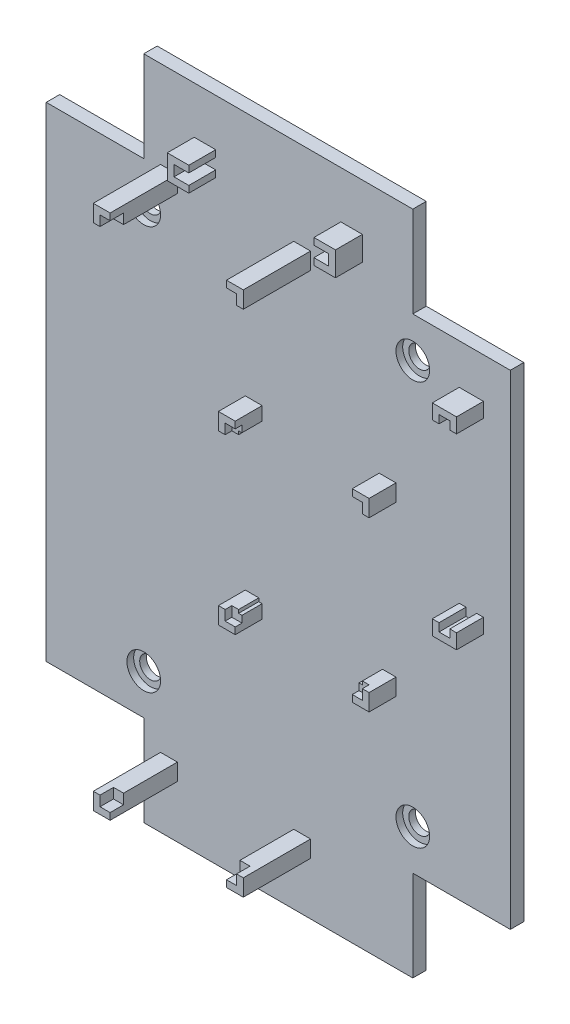
from build123d import *

# Parameters (mm, degrees)
BOSS_EXTRUDE1_DEPTH = 2
SKETCH2_R           = 1.6
CUT_EXTRUDE1_DEPTH  = 2
SKETCH5_R           = 2.5
CUT_EXTRUDE2_DEPTH  = 1
SKETCH6_W           = 25
SKETCH6_H           = 3.6
SKETCH6_W_2         = 23
SKETCH6_H_2         = 1.6
BOSS_EXTRUDE2_DEPTH = 4
SKETCH7_W           = 18.6
SKETCH7_H           = 4
CUT_EXTRUDE3_DEPTH  = 15
SKETCH9_W           = 3.6
SKETCH9_H           = 30
SKETCH9_W_2         = 1.6
SKETCH9_H_2         = 28
BOSS_EXTRUDE4_DEPTH = 4
SKETCH10_W          = 4
SKETCH10_H          = 25.6
CUT_EXTRUDE4_DEPTH  = 4
SKETCH11_W          = 22.4
SKETCH11_H          = 27.5
SKETCH11_W_2        = 20.4
SKETCH11_H_2        = 25.5
BOSS_EXTRUDE5_DEPTH = 4
SKETCH12_W          = 20.4
SKETCH12_H          = 25.5
BOSS_EXTRUDE6_DEPTH = 3
SKETCH13_W          = 18.4
SKETCH13_H          = 23.5
CUT_EXTRUDE5_DEPTH  = 3
SKETCH14_W          = 4
SKETCH14_H          = 22.5
CUT_EXTRUDE6_DEPTH  = 30
SKETCH15_W          = 17.4
SKETCH15_H          = 4
CUT_EXTRUDE7_DEPTH  = 30
SKETCH16_W          = 22.3
SKETCH16_H          = 78.2
SKETCH16_W_2        = 20.3
SKETCH16_H_2        = 76.2
BOSS_EXTRUDE7_DEPTH = 10
SKETCH17_W          = 17.3
SKETCH17_H          = 10
CUT_EXTRUDE8_DEPTH  = 10
CUT_EXTRUDE9_REACH  = 95.2
SKETCH18_W          = 17.3
SKETCH18_H          = 10
CUT_EXTRUDE10_REACH = 96.44
SKETCH19_W          = 10
SKETCH19_H          = 73.2
CUT_EXTRUDE11_REACH = 90.088
SKETCH20_W          = 10
SKETCH20_H          = 73.2
SKETCH21_W          = 1.5
SKETCH21_H          = 1.5
BOSS_EXTRUDE8_DEPTH = 8


with BuildPart() as part:
    # 3DSketch1 → Boss-Extrude1 (new body)
    with BuildSketch(Plane(origin=(-20, 20.801620861, 0), x_dir=(0.3746178943835793, -0.927179288599359, 0), z_dir=(0, 0, 1))):
        Polygon((0, 0), (14.984715775, 37.087171544), (27.501636171, 32.02982997), (32.93359564, 45.473929654), (99.690504419, 18.501441259), (94.258544951, 5.057341574), (106.775465347, 0), (91.790749571, -37.087171544), (79.273829175, -32.02982997), (73.841869707, -45.473929654), (7.084960928, -18.501441259), (12.516920396, -5.057341574), align=None)
    extrude(amount=-BOSS_EXTRUDE1_DEPTH)

    # Sketch2 → Cut-Extrude1 (cut)
    with BuildSketch(Plane.XY):
        with Locations((-20, 1.301620861)):
            Circle(SKETCH2_R)
        with Locations((20, 1.301620861)):
            Circle(SKETCH2_R)
        with Locations((20, -58.698379139)):
            Circle(SKETCH2_R)
        with Locations((-20, -58.698379139)):
            Circle(SKETCH2_R)
    extrude(amount=-CUT_EXTRUDE1_DEPTH, mode=Mode.SUBTRACT)

    # Sketch5 → Cut-Extrude2 (cut)
    with BuildSketch(Plane.XY):
        with Locations((-20, 1.301620861)):
            Circle(SKETCH5_R)
        with Locations((20, 1.301620861)):
            Circle(SKETCH5_R)
        with Locations((20, -58.698379139)):
            Circle(SKETCH5_R)
        with Locations((-20, -58.698379139)):
            Circle(SKETCH5_R)
    extrude(amount=-CUT_EXTRUDE2_DEPTH, mode=Mode.SUBTRACT)

    # Sketch6 → Boss-Extrude2 (add)
    with BuildSketch(Plane.XY):
        with Locations((0, 12.001620861)):
            Rectangle(SKETCH6_W, SKETCH6_H)
        with Locations((0, 12.001620861)):
            Rectangle(SKETCH6_W_2, SKETCH6_H_2, mode=Mode.SUBTRACT)
    extrude(amount=BOSS_EXTRUDE2_DEPTH)

    # Sketch7 → Cut-Extrude3 (cut)
    with BuildSketch(Plane(origin=(0, 13.801620861, 0), x_dir=(1, 0, 0), z_dir=(0, 1, 0))):
        with Locations((0, -2)):
            Rectangle(SKETCH7_W, SKETCH7_H)
    extrude(amount=-CUT_EXTRUDE3_DEPTH, mode=Mode.SUBTRACT)

    # Sketch9 → Boss-Extrude4 (add)
    with BuildSketch(Plane.XY):
        with Locations((28.7, -13.698379139)):
            Rectangle(SKETCH9_W, SKETCH9_H)
        with Locations((28.7, -13.698379139)):
            Rectangle(SKETCH9_W_2, SKETCH9_H_2, mode=Mode.SUBTRACT)
    extrude(amount=BOSS_EXTRUDE4_DEPTH)

    # Sketch10 → Cut-Extrude4 (cut)
    with BuildSketch(Plane(origin=(30.5, 0, 0), x_dir=(0, 0, -1), z_dir=(1, 0, 0))):
        with Locations((-2, -13.698379139)):
            Rectangle(SKETCH10_W, SKETCH10_H)
    extrude(amount=-CUT_EXTRUDE4_DEPTH, mode=Mode.SUBTRACT)

    # Sketch11 → Boss-Extrude5 (add)
    with BuildSketch(Plane.XY):
        with Locations((6.3, -29.448379139)):
            Rectangle(SKETCH11_W, SKETCH11_H)
        with Locations((6.3, -29.448379139)):
            Rectangle(SKETCH11_W_2, SKETCH11_H_2, mode=Mode.SUBTRACT)
    extrude(amount=BOSS_EXTRUDE5_DEPTH)

    # Sketch12 → Boss-Extrude6 (add)
    with BuildSketch(Plane.XY):
        with Locations((6.3, -29.448379139)):
            Rectangle(SKETCH12_W, SKETCH12_H)
    extrude(amount=BOSS_EXTRUDE6_DEPTH)

    # Sketch13 → Cut-Extrude5 (cut)
    with BuildSketch(Plane.XY.offset(3)):
        with Locations((6.3, -29.448379139)):
            Rectangle(SKETCH13_W, SKETCH13_H)
    extrude(amount=-CUT_EXTRUDE5_DEPTH, mode=Mode.SUBTRACT)

    # Sketch14 → Cut-Extrude6 (cut)
    with BuildSketch(Plane.ZY.offset(4.9)):
        with Locations((2, -29.448379139)):
            Rectangle(SKETCH14_W, SKETCH14_H)
    extrude(amount=-CUT_EXTRUDE6_DEPTH, mode=Mode.SUBTRACT)

    # Sketch15 → Cut-Extrude7 (cut)
    with BuildSketch(Plane.XZ.offset(43.198379139)):
        with Locations((6.3, 2)):
            Rectangle(SKETCH15_W, SKETCH15_H)
    extrude(amount=-CUT_EXTRUDE7_DEPTH, mode=Mode.SUBTRACT)

    # Sketch16 → Boss-Extrude7 (add)
    with BuildSketch(Plane.XY):
        with Locations((-6.35, -31.298379139)):
            Rectangle(SKETCH16_W, SKETCH16_H)
        with Locations((-6.35, -31.298379139)):
            Rectangle(SKETCH16_W_2, SKETCH16_H_2, mode=Mode.SUBTRACT)
    extrude(amount=BOSS_EXTRUDE7_DEPTH)

    # Sketch17 → Cut-Extrude8 (cut)
    with BuildSketch(Plane.XZ.offset(70.398379139)):
        with Locations((-6.35, 5)):
            Rectangle(SKETCH17_W, SKETCH17_H)
    extrude(amount=-CUT_EXTRUDE8_DEPTH, mode=Mode.SUBTRACT)

    # Sketch18 → Cut-Extrude9 (cut, up to next)
    with BuildSketch(Plane(origin=(0, 7.801620861, 0), x_dir=(1, 0, 0), z_dir=(0, 1, 0)), mode=Mode.PRIVATE) as cut_extrude9_sk1:
        with Locations((-6.35, -5)):
            Rectangle(SKETCH18_W, SKETCH18_H)
    cut_extrude9_tool1 = extrude(cut_extrude9_sk1.sketch, amount=-CUT_EXTRUDE9_REACH, mode=Mode.PRIVATE) & part.part
    add(cut_extrude9_tool1.solids().sort_by_distance((-6.35, 7.801621, 5))[0], mode=Mode.SUBTRACT)

    # Sketch19 → Cut-Extrude10 (cut, up to next)
    with BuildSketch(Plane.ZY.offset(17.5), mode=Mode.PRIVATE) as cut_extrude10_sk1:
        with Locations((5, -31.298379139)):
            Rectangle(SKETCH19_W, SKETCH19_H)
    cut_extrude10_tool1 = extrude(cut_extrude10_sk1.sketch, amount=-CUT_EXTRUDE10_REACH, mode=Mode.PRIVATE) & part.part
    add(cut_extrude10_tool1.solids().sort_by_distance((-17.5, -31.298379, 5))[0], mode=Mode.SUBTRACT)

    # Sketch20 → Cut-Extrude11 (cut, up to next)
    with BuildSketch(Plane(origin=(4.8, 0, 0), x_dir=(0, 0, -1), z_dir=(1, 0, 0)), mode=Mode.PRIVATE) as cut_extrude11_sk1:
        with Locations((-5, -31.298379139)):
            Rectangle(SKETCH20_W, SKETCH20_H)
    cut_extrude11_tool1 = extrude(cut_extrude11_sk1.sketch, amount=-CUT_EXTRUDE11_REACH, mode=Mode.PRIVATE) & part.part
    add(cut_extrude11_tool1.solids().sort_by_distance((4.8, -31.298379, 5))[0], mode=Mode.SUBTRACT)

    # Sketch21 → Boss-Extrude8 (add)
    with BuildSketch(Plane.XY):
        with Locations((-15.75, 6.051620861)):
            Rectangle(SKETCH21_W, SKETCH21_H)
        with Locations((3.05, 6.051620861)):
            Rectangle(SKETCH21_W, SKETCH21_H)
        with Locations((3.05, -68.648379139)):
            Rectangle(SKETCH21_W, SKETCH21_H)
        with Locations((-15.75, -68.648379139)):
            Rectangle(SKETCH21_W, SKETCH21_H)
    extrude(amount=BOSS_EXTRUDE8_DEPTH)


solid = part.part
